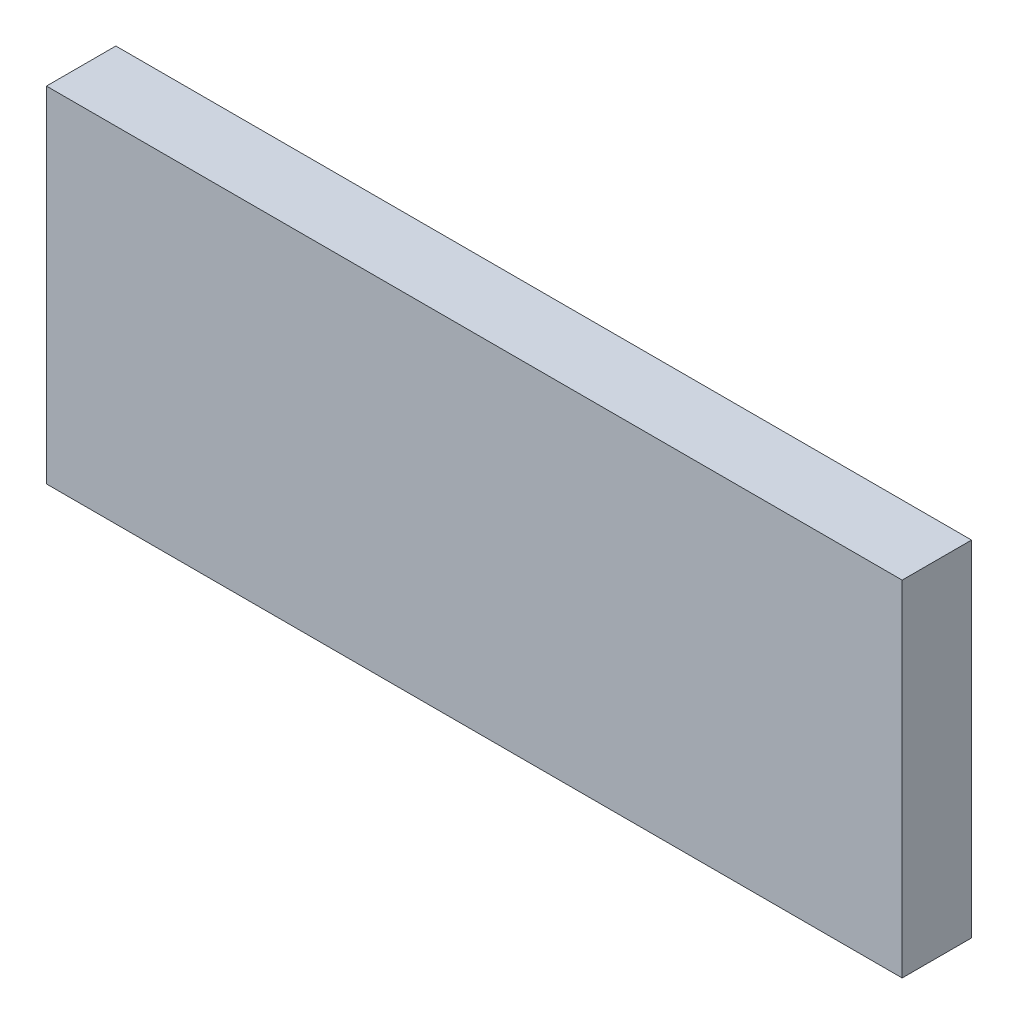
from build123d import *

# Parameters (mm, degrees)
SKETCH1_W           = 37
SKETCH1_H           = 14.9
BOSS_EXTRUDE1_DEPTH = 3


with BuildPart() as part:
    # Sketch1 → Boss-Extrude1 (new body)
    with BuildSketch(Plane.XY):
        with Locations((-6, -1.45)):
            Rectangle(SKETCH1_W, SKETCH1_H)
    extrude(amount=BOSS_EXTRUDE1_DEPTH)


solid = part.part
